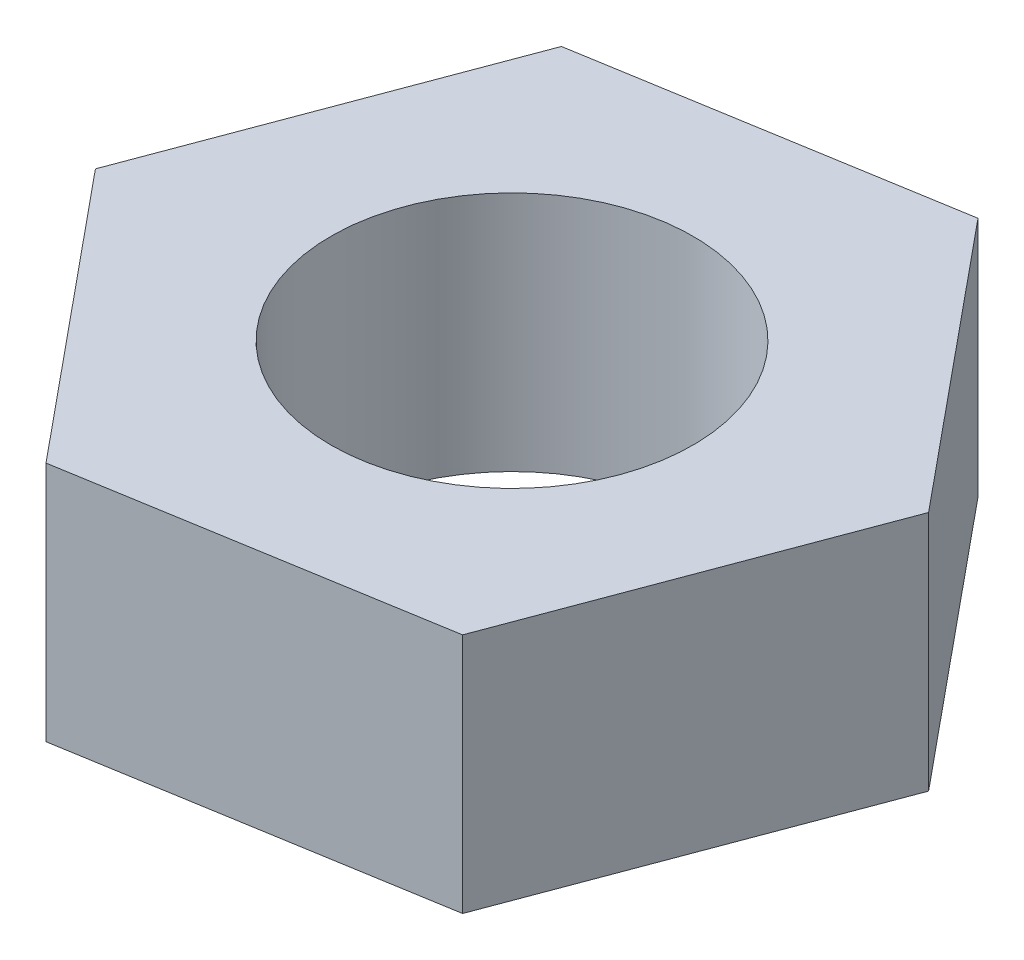
from build123d import *

# Parameters (mm, degrees)
SKETCH1_R           = 1.5
BOSS_EXTRUDE2_DEPTH = 2


with BuildPart() as part:
    # Sketch1 → Boss-Extrude2 (new body)
    with BuildSketch(Plane(origin=(0, 0, 0), x_dir=(1, 0, 0), z_dir=(0, 1, 0))):
        Polygon((2.959181771, 0.493196962), (1.052469788, 2.809325069), (-1.906711984, 2.316128108), (-2.959181771, -0.493196962), (-1.052469788, -2.809325069), (1.906711984, -2.316128108), align=None)
        Circle(SKETCH1_R, mode=Mode.SUBTRACT)
    extrude(amount=BOSS_EXTRUDE2_DEPTH)


solid = part.part
